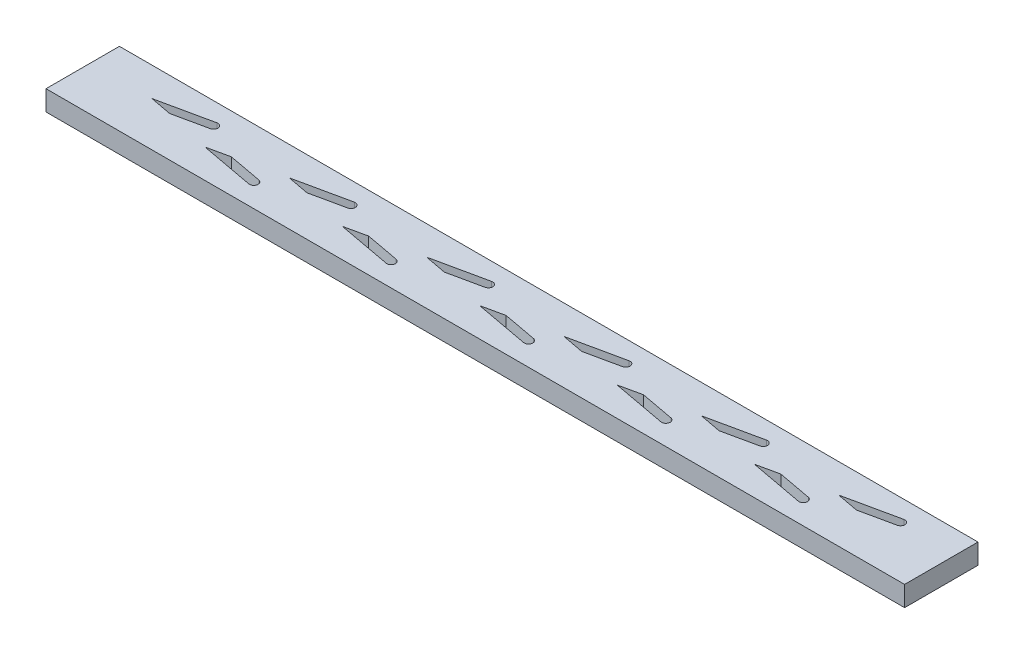
from build123d import *

# Parameters (mm, degrees)
SKETCH1_W           = 200
SKETCH1_H           = 17.1
BOSS_EXTRUDE1_DEPTH = 4.7
CUT_EXTRUDE1_DEPTH  = 4.7
LPATTERN1_COUNT     = 6
LPATTERN1_PITCH     = 32
CUT_EXTRUDE2_DEPTH  = 4.7
LPATTERN2_COUNT     = 5
LPATTERN2_PITCH     = 32


with BuildPart() as part:
    # Sketch1 → Boss-Extrude1 (new body)
    with BuildSketch(Plane(origin=(0, 0, 0), x_dir=(1, 0, 0), z_dir=(0, 1, 0))):
        with Locations((100, 8.55)):
            Rectangle(SKETCH1_W, SKETCH1_H)
    extrude(amount=BOSS_EXTRUDE1_DEPTH)

    # Sketch2 → Cut-Extrude1 (cut)
    with BuildSketch(Plane(origin=(0, 4.7, 0), x_dir=(1, 0, 0), z_dir=(0, 1, 0))):
        with BuildLine():
            Line((26.789984467, 13.027698049), (14.324334337, 10.35))
            Line((14.324334337, 10.35), (19.388431138, 9.392177684))
            Line((19.388431138, 9.392177684), (27.210015533, 11.072301951))
            ThreePointArc((27.210015533, 11.072301951), (27.977698049, 12.260015533), (26.789984467, 13.027698049))
        make_face()
    cut_extrude1 = extrude(amount=-CUT_EXTRUDE1_DEPTH, mode=Mode.SUBTRACT)

    # LPattern1: Cut-Extrude1 ×6
    with Locations(*[(i * LPATTERN1_PITCH, 0, 0) for i in range(1, LPATTERN1_COUNT)]):
        add(cut_extrude1, mode=Mode.SUBTRACT)

    # Sketch3 → Cut-Extrude2 (cut)
    with BuildSketch(Plane(origin=(0, 4.7, 0), x_dir=(1, 0, 0), z_dir=(0, 1, 0))):
        with BuildLine():
            Line((42.817010597, 4.416885114), (30.282295805, 6.75))
            Line((30.282295805, 6.75), (35.318070317, 7.847030108))
            Line((35.318070317, 7.847030108), (43.182989403, 6.383114886))
            ThreePointArc((43.182989403, 6.383114886), (43.983114886, 5.217010597), (42.817010597, 4.416885114))
        make_face()
    cut_extrude2 = extrude(amount=-CUT_EXTRUDE2_DEPTH, mode=Mode.SUBTRACT)

    # LPattern2: Cut-Extrude2 ×5
    with Locations(*[(i * LPATTERN2_PITCH, 0, 0) for i in range(1, LPATTERN2_COUNT)]):
        add(cut_extrude2, mode=Mode.SUBTRACT)


solid = part.part
